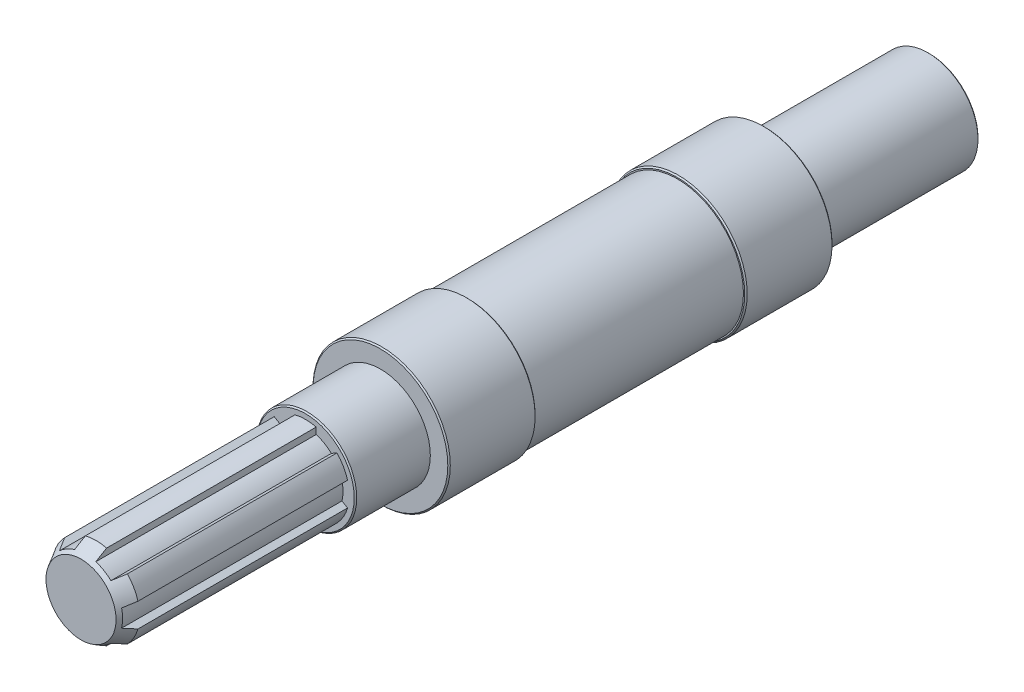
from build123d import *

# Parameters (mm, degrees)
SKICA1_R                  = 20
P_IDAT_VYSUNUT_M1_DEPTH   = 66
SKICA2_R                  = 27.5
P_IDAT_VYSUNUT_M2_DEPTH   = 35
SKICA3_R                  = 26.5
P_IDAT_VYSUNUT_M3_DEPTH   = 84
SKICA4_R                  = 27.5
P_IDAT_VYSUNUT_M4_DEPTH   = 35
SKICA5_R                  = 20
P_IDAT_VYSUNUT_M5_DEPTH   = 30
SKICA6_R                  = 17.5
P_IDAT_VYSUNUT_M6_DEPTH   = 90
ZKOSEN_3_SIZE             = 6
ZKOSEN_3_SIZE2            = 3.464101615
SKICA9_OUTSIDE_W          = 126.756
SKICA9_OUTSIDE_H          = 126.756
ODEBRAT_VYSUNUT_M16_DEPTH = 90
ZKOSEN_4_SIZE             = 0.5
M10_Z_VIT1_D              = 8.5
M10_Z_VIT1_DEPTH          = 30
M10_Z_VIT1_TIP            = 2.553657631


with BuildPart() as part:
    # Skica1 → Přidat vysunutím1 (new body)
    with BuildSketch(Plane.XY):
        Circle(SKICA1_R)
    extrude(amount=P_IDAT_VYSUNUT_M1_DEPTH)

    # Skica2 → Přidat vysunutím2 (add)
    with BuildSketch(Plane.XY.offset(66)):
        Circle(SKICA2_R)
    extrude(amount=P_IDAT_VYSUNUT_M2_DEPTH)

    # Skica3 → Přidat vysunutím3 (add)
    with BuildSketch(Plane.XY.offset(101)):
        Circle(SKICA3_R)
    extrude(amount=P_IDAT_VYSUNUT_M3_DEPTH)

    # Skica4 → Přidat vysunutím4 (add)
    with BuildSketch(Plane.XY.offset(185)):
        Circle(SKICA4_R)
    extrude(amount=P_IDAT_VYSUNUT_M4_DEPTH)

    # Skica5 → Přidat vysunutím5 (add)
    with BuildSketch(Plane.XY.offset(220)):
        Circle(SKICA5_R)
    extrude(amount=P_IDAT_VYSUNUT_M5_DEPTH)

    # Skica6 → Přidat vysunutím6 (add)
    with BuildSketch(Plane.XY.offset(250)):
        Circle(SKICA6_R)
    extrude(amount=P_IDAT_VYSUNUT_M6_DEPTH)

    # Zkosení3
    zkosen_3_edges = [part.edges().sort_by_distance(p)[0] for p in [
        (-17.5, 0, 340),
    ]]
    zkosen_3_side = [part.faces().sort_by_distance(p)[0] for p in [
        (-17.5, 0, 295),
    ]]
    chamfer(zkosen_3_edges, length=ZKOSEN_3_SIZE, length2=ZKOSEN_3_SIZE2, reference=zkosen_3_side[0])

    # Skica9 outside → Odebrat vysunutím16 (cut)
    with BuildSketch(Plane.XY.offset(340)):
        Rectangle(SKICA9_OUTSIDE_W, SKICA9_OUTSIDE_H)
        with BuildLine():
            Line((-4.25, 14.385322381), (-4.25, 16.976086121))
            ThreePointArc((-4.25, 16.976086121), (0, 17.5), (4.25, 16.976086121))
            Line((4.25, 16.976086121), (4.25, 14.385322381))
            ThreePointArc((4.25, 14.385322381), (7.5, 12.990381057), (10.333054623, 10.873269156))
            Line((10.333054623, 10.873269156), (12.576721838, 12.168651027))
            ThreePointArc((12.576721838, 12.168651027), (15.155444566, 8.75), (16.826721838, 4.807435095))
            Line((16.826721838, 4.807435095), (14.583054623, 3.512053224))
            ThreePointArc((14.583054623, 3.512053224), (15, 0), (14.583054623, -3.512053224))
            Line((14.583054623, -3.512053224), (16.826721838, -4.807435095))
            ThreePointArc((16.826721838, -4.807435095), (15.155444566, -8.75), (12.576721838, -12.168651027))
            Line((12.576721838, -12.168651027), (10.333054623, -10.873269156))
            ThreePointArc((10.333054623, -10.873269156), (7.5, -12.990381057), (4.25, -14.385322381))
            Line((4.25, -14.385322381), (4.25, -16.976086121))
            ThreePointArc((4.25, -16.976086121), (0, -17.5), (-4.25, -16.976086121))
            Line((-4.25, -16.976086121), (-4.25, -14.385322381))
            ThreePointArc((-4.25, -14.385322381), (-7.5, -12.990381057), (-10.333054623, -10.873269156))
            Line((-10.333054623, -10.873269156), (-12.576721838, -12.168651027))
            ThreePointArc((-12.576721838, -12.168651027), (-15.155444566, -8.75), (-16.826721838, -4.807435095))
            Line((-16.826721838, -4.807435095), (-14.583054623, -3.512053224))
            ThreePointArc((-14.583054623, -3.512053224), (-15, 0), (-14.583054623, 3.512053224))
            Line((-14.583054623, 3.512053224), (-16.826721838, 4.807435095))
            ThreePointArc((-16.826721838, 4.807435095), (-15.155444566, 8.75), (-12.576721838, 12.168651027))
            Line((-12.576721838, 12.168651027), (-10.333054623, 10.873269156))
            ThreePointArc((-10.333054623, 10.873269156), (-7.5, 12.990381057), (-4.25, 14.385322381))
        make_face(mode=Mode.SUBTRACT)
    extrude(amount=-ODEBRAT_VYSUNUT_M16_DEPTH, mode=Mode.SUBTRACT)

    # Zkosení4
    zkosen_4_edges = [part.edges().sort_by_distance(p)[0] for p in [
        (-27.5, 0, 185),
        (-27.5, 0, 220),
        (-20, 0, 0),
        (-20, 0, 250),
        (-27.5, 0, 66),
        (-27.5, 0, 101),
    ]]
    chamfer(zkosen_4_edges, length=ZKOSEN_4_SIZE)

    # M10 závit1
    with Locations(Plane(origin=(0, 0, 0), x_dir=(-1, 0, 0), z_dir=(0, 0, -1))):
        with Locations((0, 0)):
            Hole(M10_Z_VIT1_D / 2, depth=M10_Z_VIT1_DEPTH)
            with Locations((0, 0, -(M10_Z_VIT1_DEPTH + M10_Z_VIT1_TIP / 2))):  # 118° drill point
                Cone(0, M10_Z_VIT1_D / 2, M10_Z_VIT1_TIP, mode=Mode.SUBTRACT)


solid = part.part
